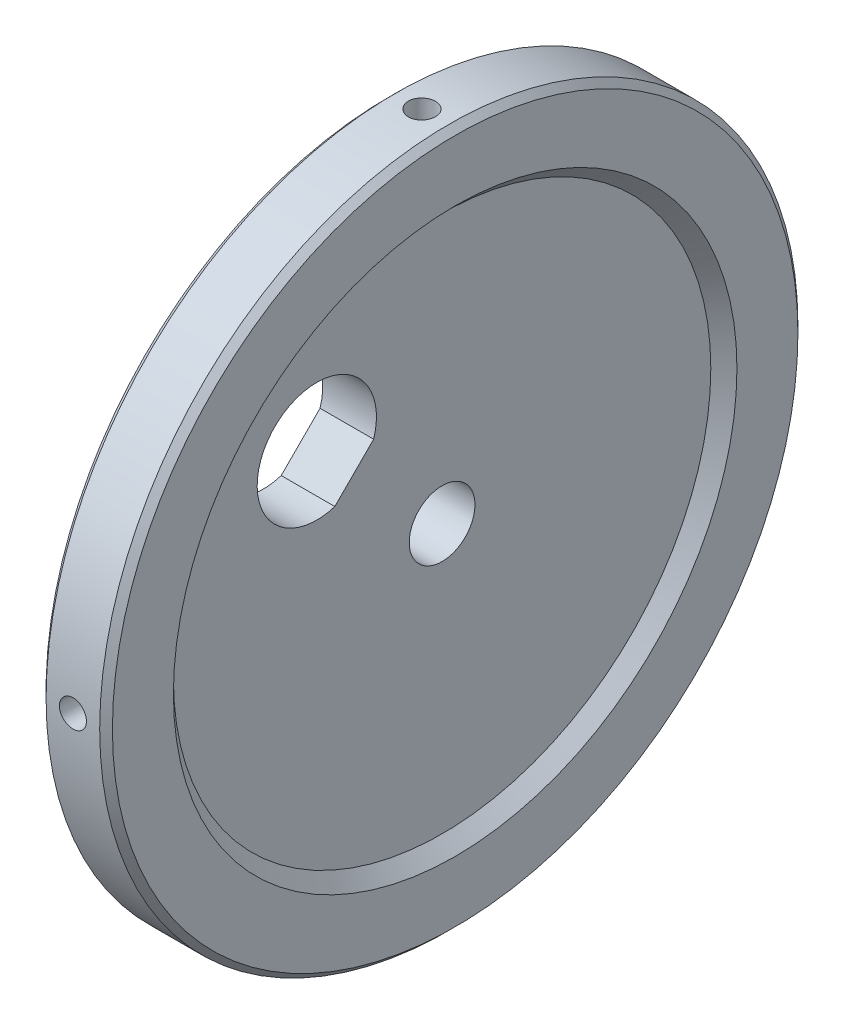
from build123d import *

# Parameters (mm, degrees)
CUT_EXTRUDE1_DEPTH = 10
CIRPATTERN2_COUNT  = 4
CHAMFER1_SIZE      = 1
CHAMFER2_SIZE      = 1
SKETCH8_R          = 52.0992
CUT_EXTRUDE2_DEPTH = 0.0508


with BuildPart() as part:
    # Sketch1 → Revolve1 (revolve)
    with BuildSketch(Plane(origin=(0, 0, 0), x_dir=(1, 0, 0), z_dir=(0, 1, 0))):
        Polygon((0, 4.9022), (0, 52.0992), (10, 52.0992), (10, 42.0992), (8, 40.0992), (8, 4.9022), align=None)
    revolve(axis=Axis((0, 0, 0), (1, 0, 0)))

    # Sketch3 → Cut-Extrude1 (cut)
    with BuildSketch(Plane(origin=(8, 0, 0), x_dir=(0, 0, -1), z_dir=(1, 0, 0))):
        with BuildLine():
            Line((-16.012131778, 10.215581079), (-10.215581079, 16.012131778))
            ThreePointArc((-10.215581079, 16.012131778), (-14.077724842, 26.305561936), (-24.993250353, 24.993250353))
            ThreePointArc((-24.993250353, 24.993250353), (-26.305561936, 14.077724842), (-16.012131778, 10.215581079))
        make_face()
    extrude(amount=-CUT_EXTRUDE1_DEPTH, mode=Mode.SUBTRACT)

    # Sketch6 → #10-32 Tapped Hole1 (revolve, cut)
    with BuildSketch(Plane(origin=(5, 0, 52.0992), x_dir=(0, -1, 0), z_dir=(1, 0, 0))):
        Polygon((0, 0), (0, 9.713317848), (2.0193, 8.5), (2.0193, 0), align=None)
    f_10_32_tapped_hole1 = revolve(axis=Axis((5, 0, 58.4492), (0, 0, -1)), mode=Mode.SUBTRACT)

    # CirPattern2: #10-32 Tapped Hole1 ×4 about axis
    cirpattern2_axis = Axis((0, 0, 0), (-1, 0, 0))
    for i in range(1, CIRPATTERN2_COUNT):
        add(f_10_32_tapped_hole1.rotate(cirpattern2_axis, i * 360 / CIRPATTERN2_COUNT), mode=Mode.SUBTRACT)

    # Chamfer1
    chamfer1_edges = [part.edges().sort_by_distance(p)[0] for p in [
        (10, 0, 52.0992),
    ]]
    chamfer(chamfer1_edges, length=CHAMFER1_SIZE)

    # Chamfer2
    chamfer2_edges = [part.edges().sort_by_distance(p)[0] for p in [
        (0, 0, 52.0992),
    ]]
    chamfer(chamfer2_edges, length=CHAMFER2_SIZE)

    # Sketch8 → Cut-Extrude2 (cut)
    with BuildSketch(Plane(origin=(10, 0, 0), x_dir=(0, 0, -1), z_dir=(1, 0, 0))):
        Circle(SKETCH8_R)
    extrude(amount=-CUT_EXTRUDE2_DEPTH, mode=Mode.SUBTRACT)


solid = part.part
